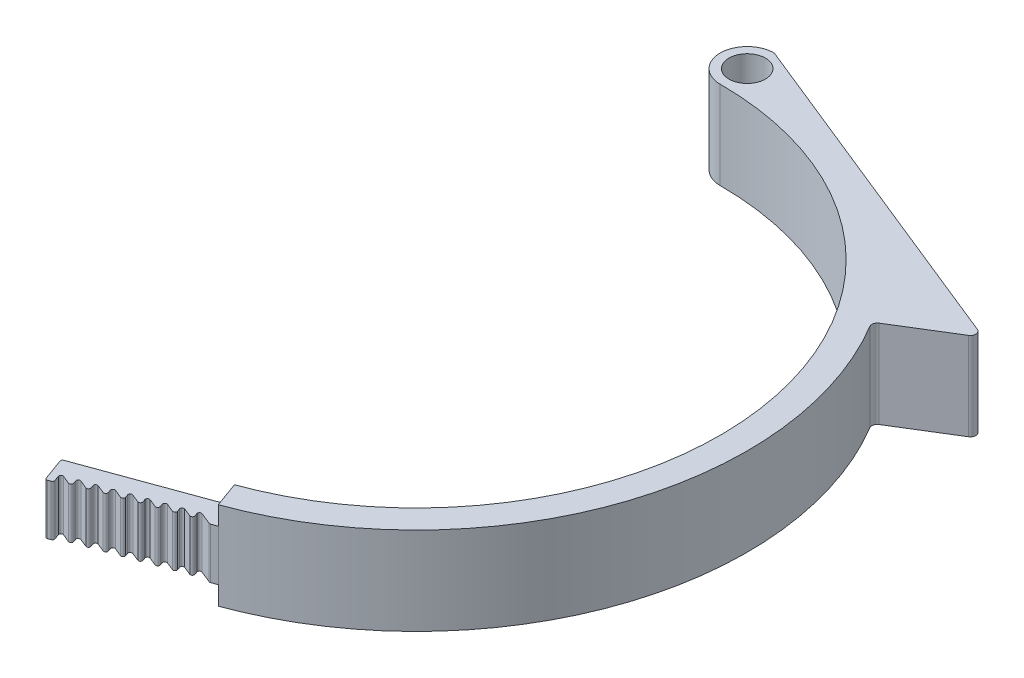
from build123d import *

# Parameters (mm, degrees)
BOSS_EXTRUDE1_DEPTH = 13
CUT_EXTRUDE1_DEPTH  = 20
FILLET2_R           = 0.3
FILLET1_R           = 0.8
SKETCH3_OUTSIDE_W   = 144.199
SKETCH3_OUTSIDE_H   = 38.986
SKETCH3_OUTSIDE_W_2 = 5.910380326
SKETCH3_OUTSIDE_H_2 = 7.5
CUT_EXTRUDE2_DEPTH  = 20


with BuildPart() as part:
    # Sketch1 → Boss-Extrude1 (new body)
    with BuildSketch(Plane(origin=(0, 0, 0), x_dir=(1, 0, 0), z_dir=(0, 1, 0))):
        with BuildLine():
            Line((0, 51.7), (0, 53))
            ThreePointArc((0, 53), (-4, 49), (0, 45))
            ThreePointArc((0, 45), (44.316348886, 7.814167995), (15.39090645, -42.286167935))
            Line((15.39090645, -42.286167935), (-3.402945966, -49.126570802))
            Line((-3.402945966, -49.126570802), (-2.034865393, -52.885341285))
            Line((-2.034865393, -52.885341285), (16.758987023, -46.044938419))
            ThreePointArc((16.758987023, -46.044938419), (46.283080581, -16.089638031), (41.707047143, 25.720074234))
            ThreePointArc((41.707047143, 25.720074234), (25.051905135, 42.111780407), (2.698975076, 48.925612245))
            ThreePointArc((2.698975076, 48.925612245), (-1.935309657, 47.117295421), (0, 51.7))
        make_face()
        with BuildLine():
            Line((51.921017872, 32.018867925), (0, 53))
            Line((0, 53), (0, 51.7))
            ThreePointArc((0, 51.7), (1.909188309, 50.909188309), (2.7, 49))
            ThreePointArc((2.7, 49), (2.699743757, 48.962802592), (2.698975076, 48.925612245))
            ThreePointArc((2.698975076, 48.925612245), (25.051905135, 42.111780407), (41.707047143, 25.720074234))
            Line((41.707047143, 25.720074234), (51.921017872, 32.018867925))
        make_face()
    extrude(amount=BOSS_EXTRUDE1_DEPTH)

    # Sketch2 → Cut-Extrude1 (cut)
    with BuildSketch(Plane(origin=(0, 13, 0), x_dir=(1, 0, 0), z_dir=(0, 1, 0))):
        Polygon((-1.71080903, -50.851874424), (-1.095172772, -52.543321142), (0.78421247, -51.859280855), align=None)
        Polygon((0.168576212, -50.167834138), (0.78421247, -51.859280855), (2.663597711, -51.175240568), align=None)
        Polygon((2.047961453, -49.483793851), (2.663597711, -51.175240568), (4.542982953, -50.491200282), align=None)
        Polygon((3.927346695, -48.799753564), (4.542982953, -50.491200282), (6.422368194, -49.807159995), align=None)
        Polygon((5.806731936, -48.115713278), (6.422368194, -49.807159995), (8.301753436, -49.123119708), align=None)
        Polygon((7.686117178, -47.431672991), (8.301753436, -49.123119708), (10.181138677, -48.439079422), align=None)
        Polygon((9.565502419, -46.747632704), (10.181138677, -48.439079422), (12.060523919, -47.755039135), align=None)
        Polygon((11.444887661, -46.063592418), (12.060523919, -47.755039135), (13.939909161, -47.070998848), align=None)
        Polygon((13.324272903, -45.379552131), (13.939909161, -47.070998848), (15.819294402, -46.386958562), align=None)
    extrude(amount=-CUT_EXTRUDE1_DEPTH, mode=Mode.SUBTRACT)

    # Fillet2
    fillet2_edges = [part.edges().sort_by_distance(p)[0] for p in [
        (0.168576212, 6.5, 50.167834138),
        (3.927346695, 6.5, 48.799753564),
        (7.686117178, 6.5, 47.431672991),
        (11.444887661, 6.5, 46.063592418),
        (-2.034865393, 6.5, 52.885341285),
        (-3.402945966, 6.5, 49.126570802),
        (-1.71080903, 6.5, 50.851874424),
        (0.78421247, 6.5, 51.859280855),
        (-1.095172772, 6.5, 52.543321142),
        (2.047961453, 6.5, 49.483793851),
        (4.542982953, 6.5, 50.491200282),
        (2.663597711, 6.5, 51.175240568),
        (5.806731936, 6.5, 48.115713278),
        (8.301753436, 6.5, 49.123119708),
        (6.422368194, 6.5, 49.807159995),
        (9.565502419, 6.5, 46.747632704),
        (12.060523919, 6.5, 47.755039135),
        (10.181138677, 6.5, 48.439079422),
        (13.324272903, 6.5, 45.379552131),
        (15.819294402, 6.5, 46.386958562),
        (13.939909161, 6.5, 47.070998848),
    ]]
    fillet(fillet2_edges, radius=FILLET2_R)

    # Fillet1
    fillet1_edges = [part.edges().sort_by_distance(p)[0] for p in [
        (51.921017872, 6.5, -32.018867925),
        (41.707047143, 6.5, -25.720074234),
        (0, 6.5, -53),
    ]]
    fillet(fillet1_edges, radius=FILLET1_R)

    # Sketch3 outside → Cut-Extrude2 (cut)
    with BuildSketch(Plane(origin=(-18.793852416, 0, 6.840402867), x_dir=(0.342020143, 0, 0.939692621), z_dir=(-0.939692621, 0, 0.342020143))):
        with Locations((7.9375, 6.5)):
            Rectangle(SKETCH3_OUTSIDE_W, SKETCH3_OUTSIDE_H)
        with Locations((47.141631591, 6.5)):
            Rectangle(SKETCH3_OUTSIDE_W_2, SKETCH3_OUTSIDE_H_2, mode=Mode.SUBTRACT)
    extrude(amount=-CUT_EXTRUDE2_DEPTH, mode=Mode.SUBTRACT)


solid = part.part
